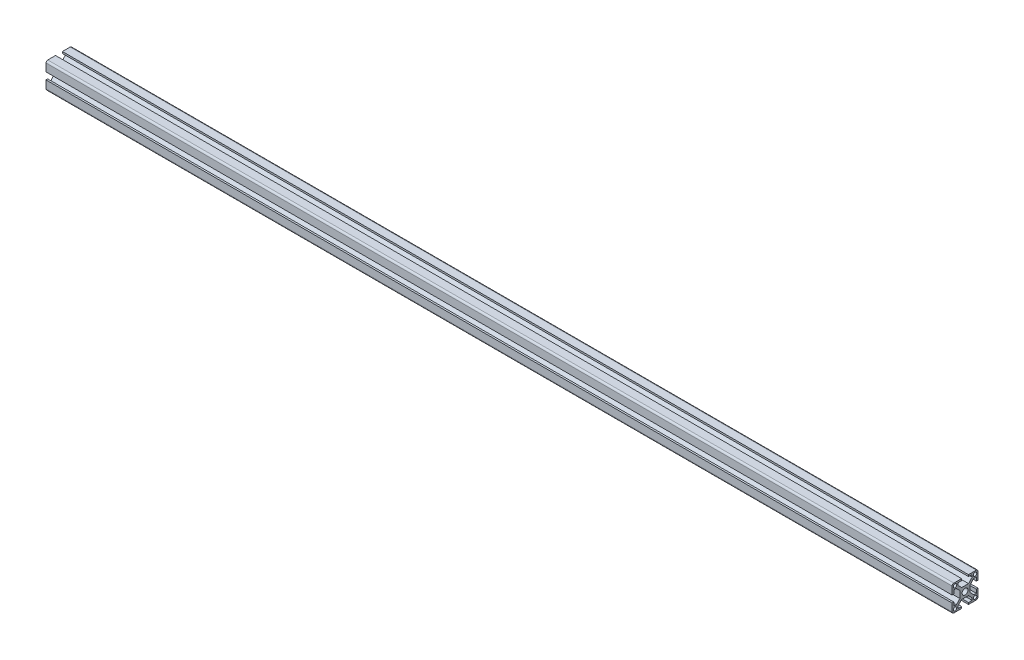
from build123d import *

# Parameters (mm, degrees)
SKETCH11_R                = 3.4
SKETCH11_R_2              = 2
NEW_ALUM_ALUM3BY3_1_DEPTH = 1050
SKETCH12_R                = 2.5
CUT_EXTRUDE1_DEPTH        = 707.780320658


with BuildPart() as part:
    # Sketch11 → New alum ALUM3BY3(1) (new body)
    with BuildSketch(Plane.YZ.offset(-343.690987124)):
        with BuildLine():
            Line((-4, 6), (4, 6))
            Line((4, 6), (8.25, 10.106126974))
            Line((8.25, 10.106126974), (8.25, 13))
            Line((8.25, 13), (4, 13))
            Line((4, 13), (4, 15))
            Line((4, 15), (13, 15))
            ThreePointArc((13, 15), (14.414213562, 14.414213562), (15, 13))
            Line((15, 13), (15, 4))
            Line((15, 4), (13, 4))
            Line((13, 4), (13, 8.25))
            Line((13, 8.25), (10.398914138, 8.25))
            Line((10.398914138, 8.25), (6, 4))
            Line((6, 4), (6, -4))
            Line((6, -4), (10.398914138, -8.25))
            Line((10.398914138, -8.25), (13, -8.25))
            Line((13, -8.25), (13, -4))
            Line((13, -4), (15, -4))
            Line((15, -4), (15, -13))
            ThreePointArc((15, -13), (14.414213562, -14.414213562), (13, -15))
            Line((13, -15), (4, -15))
            Line((4, -15), (4, -13))
            Line((4, -13), (8.25, -13))
            Line((8.25, -13), (8.25, -10.106126974))
            Line((8.25, -10.106126974), (4, -6))
            Line((4, -6), (-4, -6))
            Line((-4, -6), (-8.25, -10.106126974))
            Line((-8.25, -10.106126974), (-8.25, -13))
            Line((-8.25, -13), (-4, -13))
            Line((-4, -13), (-4, -15))
            Line((-4, -15), (-13, -15))
            ThreePointArc((-13, -15), (-14.414213562, -14.414213562), (-15, -13))
            Line((-15, -13), (-15, -4))
            Line((-15, -4), (-13, -4))
            Line((-13, -4), (-13, -8.25))
            Line((-13, -8.25), (-10.398914138, -8.25))
            Line((-10.398914138, -8.25), (-6, -4))
            Line((-6, -4), (-6, 4))
            Line((-6, 4), (-10.398914138, 8.25))
            Line((-10.398914138, 8.25), (-13, 8.25))
            Line((-13, 8.25), (-13, 4))
            Line((-13, 4), (-15, 4))
            Line((-15, 4), (-15, 13))
            ThreePointArc((-15, 13), (-14.414213562, 14.414213562), (-13, 15))
            Line((-13, 15), (-4, 15))
            Line((-4, 15), (-4, 13))
            Line((-4, 13), (-8.25, 13))
            Line((-8.25, 13), (-8.25, 10.106126974))
            Line((-8.25, 10.106126974), (-4, 6))
        make_face()
        Circle(SKETCH11_R, mode=Mode.SUBTRACT)
        with Locations((11.6, 11.6)):
            Circle(SKETCH11_R_2, mode=Mode.SUBTRACT)
        with Locations((-11.6, 11.6)):
            Circle(SKETCH11_R_2, mode=Mode.SUBTRACT)
        with Locations((11.6, -11.6)):
            Circle(SKETCH11_R_2, mode=Mode.SUBTRACT)
        with Locations((-11.6, -11.6)):
            Circle(SKETCH11_R_2, mode=Mode.SUBTRACT)
    extrude(amount=NEW_ALUM_ALUM3BY3_1_DEPTH)

    # Sketch12 → Cut-Extrude1 (cut, through all)
    with BuildSketch(Plane.XY.offset(6)):
        with Locations((-268.690987124, 0)):
            Circle(SKETCH12_R)
        with Locations((-168.690987124, 0)):
            Circle(SKETCH12_R)
        with Locations((-78.730987124, 0)):
            Circle(SKETCH12_R)
    extrude(amount=-CUT_EXTRUDE1_DEPTH, mode=Mode.SUBTRACT)


solid = part.part
